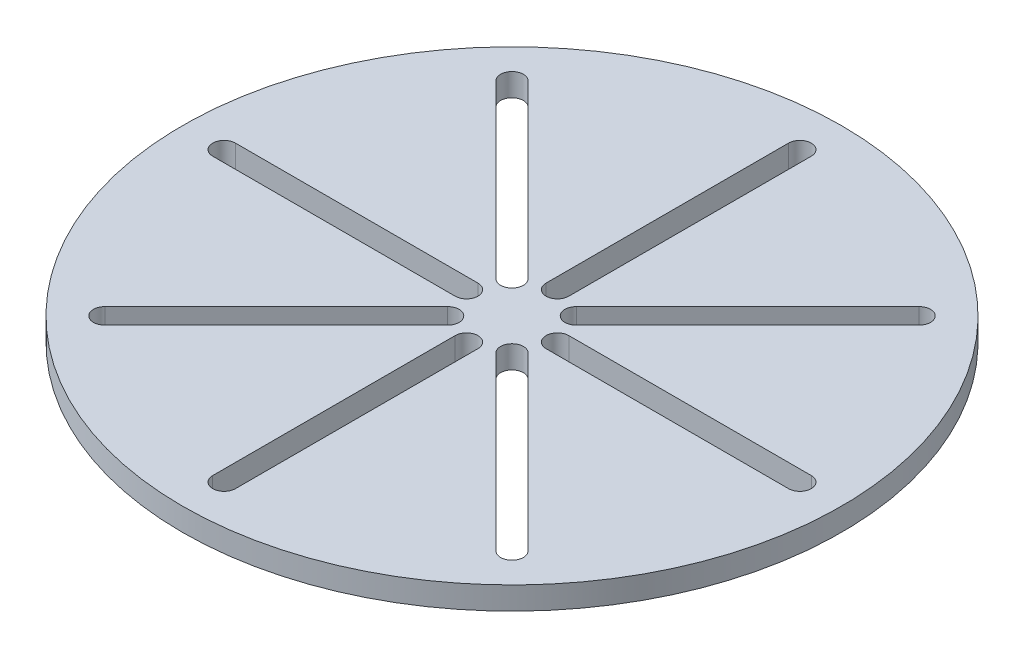
from build123d import *

# Parameters (mm, degrees)
SKETCH1_R           = 69.05625
BOSS_EXTRUDE1_DEPTH = 4.7625


with BuildPart() as part:
    # Sketch1 → Boss-Extrude1 (new body)
    with BuildSketch(Plane(origin=(0, 0, 0), x_dir=(1, 0, 0), z_dir=(0, 1, 0))):
        with Locations((5.08, -4.445)):
            Circle(SKETCH1_R)
        with BuildLine():
            Line((2.69875, 5.08), (2.69875, 55.88))
            ThreePointArc((2.69875, 55.88), (5.08, 58.26125), (7.46125, 55.88))
            Line((7.46125, 55.88), (7.46125, 5.08))
            ThreePointArc((7.46125, 5.08), (5.08, 2.69875), (2.69875, 5.08))
        make_face(mode=Mode.SUBTRACT)
        with BuildLine():
            Line((10.131394068, 3.973990114), (46.052418552, 39.895014598))
            ThreePointArc((46.052418552, 39.895014598), (49.420014598, 39.895014598), (49.420014598, 36.527418552))
            Line((49.420014598, 36.527418552), (13.498990114, 0.606394068))
            ThreePointArc((13.498990114, 0.606394068), (10.131394068, 0.606394068), (10.131394068, 3.973990114))
        make_face(mode=Mode.SUBTRACT)
        with BuildLine():
            Line((14.605, -2.06375), (65.405, -2.06375))
            ThreePointArc((65.405, -2.06375), (67.78625, -4.445), (65.405, -6.82625))
            Line((65.405, -6.82625), (14.605, -6.82625))
            ThreePointArc((14.605, -6.82625), (12.22375, -4.445), (14.605, -2.06375))
        make_face(mode=Mode.SUBTRACT)
        with BuildLine():
            Line((13.498990114, -9.496394068), (49.420014598, -45.417418552))
            ThreePointArc((49.420014598, -45.417418552), (49.420014598, -48.785014598), (46.052418552, -48.785014598))
            Line((46.052418552, -48.785014598), (10.131394068, -12.863990114))
            ThreePointArc((10.131394068, -12.863990114), (10.131394068, -9.496394068), (13.498990114, -9.496394068))
        make_face(mode=Mode.SUBTRACT)
        with BuildLine():
            Line((7.46125, -13.97), (7.46125, -64.77))
            ThreePointArc((7.46125, -64.77), (5.08, -67.15125), (2.69875, -64.77))
            Line((2.69875, -64.77), (2.69875, -13.97))
            ThreePointArc((2.69875, -13.97), (5.08, -11.58875), (7.46125, -13.97))
        make_face(mode=Mode.SUBTRACT)
        with BuildLine():
            Line((0.028605932, -12.863990114), (-35.892418552, -48.785014598))
            ThreePointArc((-35.892418552, -48.785014598), (-39.260014598, -48.785014598), (-39.260014598, -45.417418552))
            Line((-39.260014598, -45.417418552), (-3.338990114, -9.496394068))
            ThreePointArc((-3.338990114, -9.496394068), (0.028605932, -9.496394068), (0.028605932, -12.863990114))
        make_face(mode=Mode.SUBTRACT)
        with BuildLine():
            Line((-4.445, -6.82625), (-55.245, -6.82625))
            ThreePointArc((-55.245, -6.82625), (-57.62625, -4.445), (-55.245, -2.06375))
            Line((-55.245, -2.06375), (-4.445, -2.06375))
            ThreePointArc((-4.445, -2.06375), (-2.06375, -4.445), (-4.445, -6.82625))
        make_face(mode=Mode.SUBTRACT)
        with BuildLine():
            Line((-3.338990114, 0.606394068), (-39.260014598, 36.527418552))
            ThreePointArc((-39.260014598, 36.527418552), (-39.260014598, 39.895014598), (-35.892418552, 39.895014598))
            Line((-35.892418552, 39.895014598), (0.028605932, 3.973990114))
            ThreePointArc((0.028605932, 3.973990114), (0.028605932, 0.606394068), (-3.338990114, 0.606394068))
        make_face(mode=Mode.SUBTRACT)
    extrude(amount=BOSS_EXTRUDE1_DEPTH)


solid = part.part
